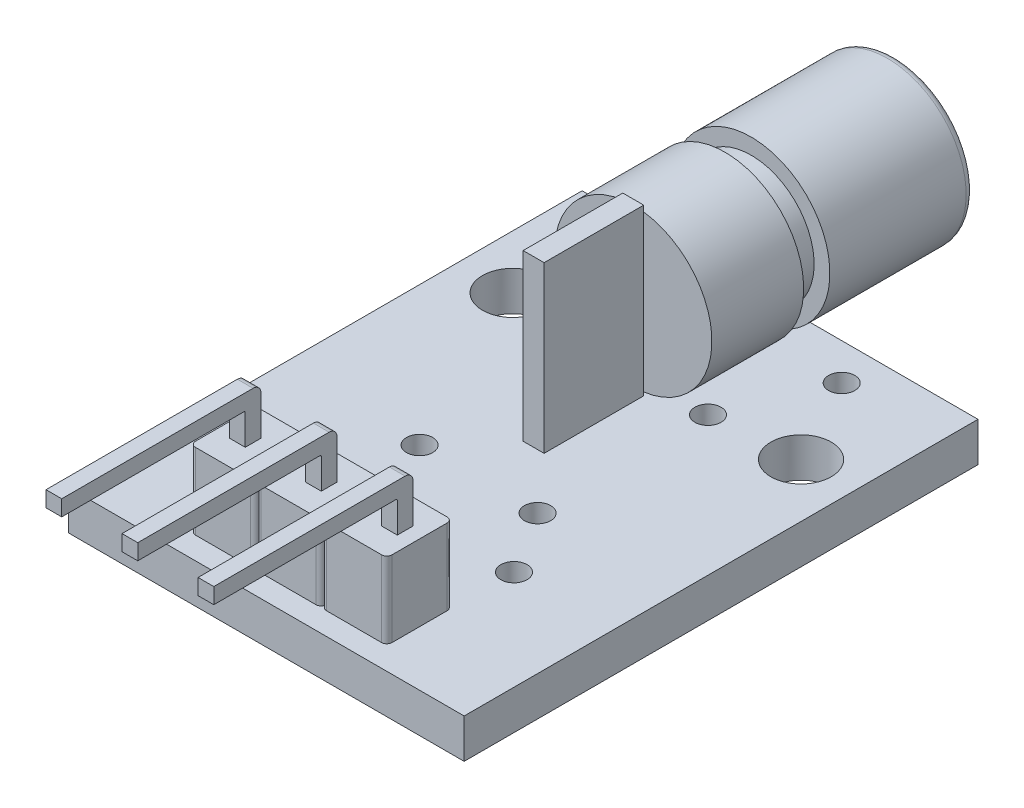
from build123d import *

# Parameters (mm, degrees)
SKETCH1_W           = 15.1
SKETCH1_H           = 19.6
BOSS_EXTRUDE1_DEPTH = 1.5
SKETCH2_W           = 0.6
SKETCH2_H           = 0.6
BOSS_EXTRUDE2_DEPTH = 1.7
BOSS_EXTRUDE3_DEPTH = 2.9
SKETCH4_W           = 0.6
SKETCH4_H           = 0.6
BOSS_EXTRUDE4_DEPTH = 1.8
SKETCH5_W           = 0.6
SKETCH5_H           = 0.6
BOSS_EXTRUDE5_DEPTH = 7
SKETCH7_W           = 0.8
SKETCH7_H           = 3.8
BOSS_EXTRUDE6_DEPTH = 6.3
SKETCH8_R           = 3
BOSS_EXTRUDE7_DEPTH = 3.5
SKETCH9_R           = 2.4
BOSS_EXTRUDE8_DEPTH = 1
SKETCH10_R          = 3
BOSS_EXTRUDE9_DEPTH = 5.5
FILLET1_R           = 0.3
SKETCH11_R          = 1.5
CUT_EXTRUDE1_DEPTH  = 1
SKETCH12_R          = 1.15
CUT_EXTRUDE2_DEPTH  = 4.2
CUT_EXTRUDE3_REACH  = 9.8
SKETCH13_R          = 0.5
CUT_EXTRUDE4_REACH  = 9.8
SKETCH14_R          = 0.5
FILLET2_R           = 0.2
FILLET3_R           = 0.05
FILLET5_R           = 0.3


with BuildPart() as part:
    # Sketch1 → Boss-Extrude1 (new body)
    with BuildSketch(Plane(origin=(0, 0, 0), x_dir=(1, 0, 0), z_dir=(0, 1, 0))):
        Rectangle(SKETCH1_W, SKETCH1_H)
    extrude(amount=BOSS_EXTRUDE1_DEPTH)

    # Sketch2 → Boss-Extrude2 (add)
    with BuildSketch(Plane.XZ):
        with Locations((0, 7.7)):
            Rectangle(SKETCH2_W, SKETCH2_H)
        with Locations((2.9, 7.7)):
            Rectangle(SKETCH2_W, SKETCH2_H)
        with Locations((-2.9, 7.7)):
            Rectangle(SKETCH2_W, SKETCH2_H)
    extrude(amount=BOSS_EXTRUDE2_DEPTH)

    # Sketch3 → Boss-Extrude3 (add)
    with BuildSketch(Plane(origin=(0, 1.5, 0), x_dir=(1, 0, 0), z_dir=(0, 1, 0))):
        with BuildLine():
            Line((-3.75, -8.95), (-3.75, -6.45))
            Line((-3.75, -6.45), (-1.45, -6.45))
            ThreePointArc((-1.45, -6.45), (-1.308578644, -6.508578644), (-1.25, -6.65))
            ThreePointArc((-1.25, -6.65), (-1.191421356, -6.508578644), (-1.05, -6.45))
            Line((-1.05, -6.45), (1.05, -6.45))
            ThreePointArc((1.05, -6.45), (1.191421356, -6.508578644), (1.25, -6.65))
            ThreePointArc((1.25, -6.65), (1.308578644, -6.508578644), (1.45, -6.45))
            Line((1.45, -6.45), (3.75, -6.45))
            Line((3.75, -6.45), (3.75, -8.95))
            Line((3.75, -8.95), (1.45, -8.95))
            ThreePointArc((1.45, -8.95), (1.308578644, -8.891421356), (1.25, -8.75))
            ThreePointArc((1.25, -8.75), (1.191421356, -8.891421356), (1.05, -8.95))
            Line((1.05, -8.95), (-1.05, -8.95))
            ThreePointArc((-1.05, -8.95), (-1.191421356, -8.891421356), (-1.25, -8.75))
            ThreePointArc((-1.25, -8.75), (-1.308578644, -8.891421356), (-1.45, -8.95))
            Line((-1.45, -8.95), (-3.75, -8.95))
        make_face()
    extrude(amount=BOSS_EXTRUDE3_DEPTH)

    # Sketch4 → Boss-Extrude4 (add)
    with BuildSketch(Plane(origin=(0, 4.4, 0), x_dir=(1, 0, 0), z_dir=(0, 1, 0))):
        with Locations((-2.9, -7.7)):
            Rectangle(SKETCH4_W, SKETCH4_H)
        with Locations((0, -7.7)):
            Rectangle(SKETCH4_W, SKETCH4_H)
        with Locations((2.9, -7.7)):
            Rectangle(SKETCH4_W, SKETCH4_H)
    extrude(amount=BOSS_EXTRUDE4_DEPTH)

    # Sketch5 → Boss-Extrude5 (add)
    with BuildSketch(Plane.XY.offset(8)):
        with Locations((-2.9, 5.9)):
            Rectangle(SKETCH5_W, SKETCH5_H)
        with Locations((0, 5.9)):
            Rectangle(SKETCH5_W, SKETCH5_H)
        with Locations((2.9, 5.9)):
            Rectangle(SKETCH5_W, SKETCH5_H)
    extrude(amount=BOSS_EXTRUDE5_DEPTH)

    # Sketch7 → Boss-Extrude6 (add)
    with BuildSketch(Plane(origin=(0, 1.5, 0), x_dir=(1, 0, 0), z_dir=(0, 1, 0))):
        with Locations((0, 2.3)):
            Rectangle(SKETCH7_W, SKETCH7_H)
    extrude(amount=BOSS_EXTRUDE6_DEPTH)

    # Sketch8 → Boss-Extrude7 (add)
    with BuildSketch(Plane(origin=(0, 0, -4.2), x_dir=(-1, 0, 0), z_dir=(0, 0, -1))):
        with Locations((0, 4.6)):
            Circle(SKETCH8_R)
    extrude(amount=BOSS_EXTRUDE7_DEPTH)

    # Sketch9 → Boss-Extrude8 (add)
    with BuildSketch(Plane(origin=(0, 0, -7.7), x_dir=(-1, 0, 0), z_dir=(0, 0, -1))):
        with Locations((0, 4.6)):
            Circle(SKETCH9_R)
    extrude(amount=BOSS_EXTRUDE8_DEPTH)

    # Sketch10 → Boss-Extrude9 (add)
    with BuildSketch(Plane(origin=(0, 0, -8.7), x_dir=(-1, 0, 0), z_dir=(0, 0, -1))):
        with Locations((0, 4.6)):
            Circle(SKETCH10_R)
    extrude(amount=BOSS_EXTRUDE9_DEPTH)

    # Fillet1
    fillet1_edges = [part.edges().sort_by_distance(p)[0] for p in [
        (3, 4.6, -14.2),
    ]]
    fillet(fillet1_edges, radius=FILLET1_R)

    # Sketch11 → Cut-Extrude1 (cut)
    with BuildSketch(Plane(origin=(0, 0, -14.2), x_dir=(-1, 0, 0), z_dir=(0, 0, -1))):
        with Locations((0, 4.6)):
            Circle(SKETCH11_R)
    extrude(amount=-CUT_EXTRUDE1_DEPTH, mode=Mode.SUBTRACT)

    # Sketch12 → Cut-Extrude2 (cut, through all)
    with BuildSketch(Plane(origin=(0, 1.5, 0), x_dir=(1, 0, 0), z_dir=(0, 1, 0))):
        with Locations((-5.5, 5.1)):
            Circle(SKETCH12_R)
        with Locations((5.5, 5.1)):
            Circle(SKETCH12_R)
    extrude(amount=-CUT_EXTRUDE2_DEPTH, mode=Mode.SUBTRACT)

    # Sketch13 → Cut-Extrude3 (cut, up to next)
    with BuildSketch(Plane.XZ, mode=Mode.PRIVATE) as cut_extrude3_sk1:
        with Locations((-2.25, -4.8)):
            Circle(SKETCH13_R)
    cut_extrude3_tool1 = extrude(cut_extrude3_sk1.sketch, amount=-CUT_EXTRUDE3_REACH, mode=Mode.PRIVATE) & part.part
    add(cut_extrude3_tool1.solids().sort_by_distance((-2.25, 0, -4.8))[0], mode=Mode.SUBTRACT)
    # Sketch13 → Cut-Extrude3 (cut, up to next)
    with BuildSketch(Plane.XZ, mode=Mode.PRIVATE) as cut_extrude3_sk2:
        with Locations((2.25, -4.8)):
            Circle(SKETCH13_R)
    cut_extrude3_tool2 = extrude(cut_extrude3_sk2.sketch, amount=-CUT_EXTRUDE3_REACH, mode=Mode.PRIVATE) & part.part
    add(cut_extrude3_tool2.solids().sort_by_distance((2.25, 0, -4.8))[0], mode=Mode.SUBTRACT)
    # Sketch13 → Cut-Extrude3 (cut, up to next)
    with BuildSketch(Plane.XZ, mode=Mode.PRIVATE) as cut_extrude3_sk3:
        with Locations((2.25, 1.7)):
            Circle(SKETCH13_R)
    cut_extrude3_tool3 = extrude(cut_extrude3_sk3.sketch, amount=-CUT_EXTRUDE3_REACH, mode=Mode.PRIVATE) & part.part
    add(cut_extrude3_tool3.solids().sort_by_distance((2.25, 0, 1.7))[0], mode=Mode.SUBTRACT)
    # Sketch13 → Cut-Extrude3 (cut, up to next)
    with BuildSketch(Plane.XZ, mode=Mode.PRIVATE) as cut_extrude3_sk4:
        with Locations((-2.25, 1.7)):
            Circle(SKETCH13_R)
    cut_extrude3_tool4 = extrude(cut_extrude3_sk4.sketch, amount=-CUT_EXTRUDE3_REACH, mode=Mode.PRIVATE) & part.part
    add(cut_extrude3_tool4.solids().sort_by_distance((-2.25, 0, 1.7))[0], mode=Mode.SUBTRACT)

    # Sketch14 → Cut-Extrude4 (cut, up to next)
    with BuildSketch(Plane.XZ, mode=Mode.PRIVATE) as cut_extrude4_sk1:
        with Locations((3.75, 4.1)):
            Circle(SKETCH14_R)
    cut_extrude4_tool1 = extrude(cut_extrude4_sk1.sketch, amount=-CUT_EXTRUDE4_REACH, mode=Mode.PRIVATE) & part.part
    add(cut_extrude4_tool1.solids().sort_by_distance((3.75, 0, 4.1))[0], mode=Mode.SUBTRACT)
    # Sketch14 → Cut-Extrude4 (cut, up to next)
    with BuildSketch(Plane.XZ, mode=Mode.PRIVATE) as cut_extrude4_sk2:
        with Locations((-3.75, 4.1)):
            Circle(SKETCH14_R)
    cut_extrude4_tool2 = extrude(cut_extrude4_sk2.sketch, amount=-CUT_EXTRUDE4_REACH, mode=Mode.PRIVATE) & part.part
    add(cut_extrude4_tool2.solids().sort_by_distance((-3.75, 0, 4.1))[0], mode=Mode.SUBTRACT)
    # Sketch14 → Cut-Extrude4 (cut, up to next)
    with BuildSketch(Plane.XZ, mode=Mode.PRIVATE) as cut_extrude4_sk3:
        with Locations((-3.75, -8.4)):
            Circle(SKETCH14_R)
    cut_extrude4_tool3 = extrude(cut_extrude4_sk3.sketch, amount=-CUT_EXTRUDE4_REACH, mode=Mode.PRIVATE) & part.part
    add(cut_extrude4_tool3.solids().sort_by_distance((-3.75, 0, -8.4))[0], mode=Mode.SUBTRACT)
    # Sketch14 → Cut-Extrude4 (cut, up to next)
    with BuildSketch(Plane.XZ, mode=Mode.PRIVATE) as cut_extrude4_sk4:
        with Locations((3.75, -8.4)):
            Circle(SKETCH14_R)
    cut_extrude4_tool4 = extrude(cut_extrude4_sk4.sketch, amount=-CUT_EXTRUDE4_REACH, mode=Mode.PRIVATE) & part.part
    add(cut_extrude4_tool4.solids().sort_by_distance((3.75, 0, -8.4))[0], mode=Mode.SUBTRACT)

    # Fillet2
    fillet2_edges = [part.edges().sort_by_distance(p)[0] for p in [
        (-3.75, 2.95, 8.95),
        (3.75, 2.95, 8.95),
        (3.75, 2.95, 6.45),
        (-3.75, 2.95, 6.45),
    ]]
    fillet(fillet2_edges, radius=FILLET2_R)

    # Fillet3
    fillet3_edges = [part.edges().sort_by_distance(p)[0] for p in [
        (-2.9, 5.6, 8),
        (0, 5.6, 8),
        (2.9, 5.6, 8),
    ]]
    fillet(fillet3_edges, radius=FILLET3_R)

    # Fillet5
    fillet5_edges = [part.edges().sort_by_distance(p)[0] for p in [
        (0, 6.2, 7.4),
        (2.9, 6.2, 7.4),
        (-2.9, 6.2, 7.4),
    ]]
    fillet(fillet5_edges, radius=FILLET5_R)


solid = part.part
